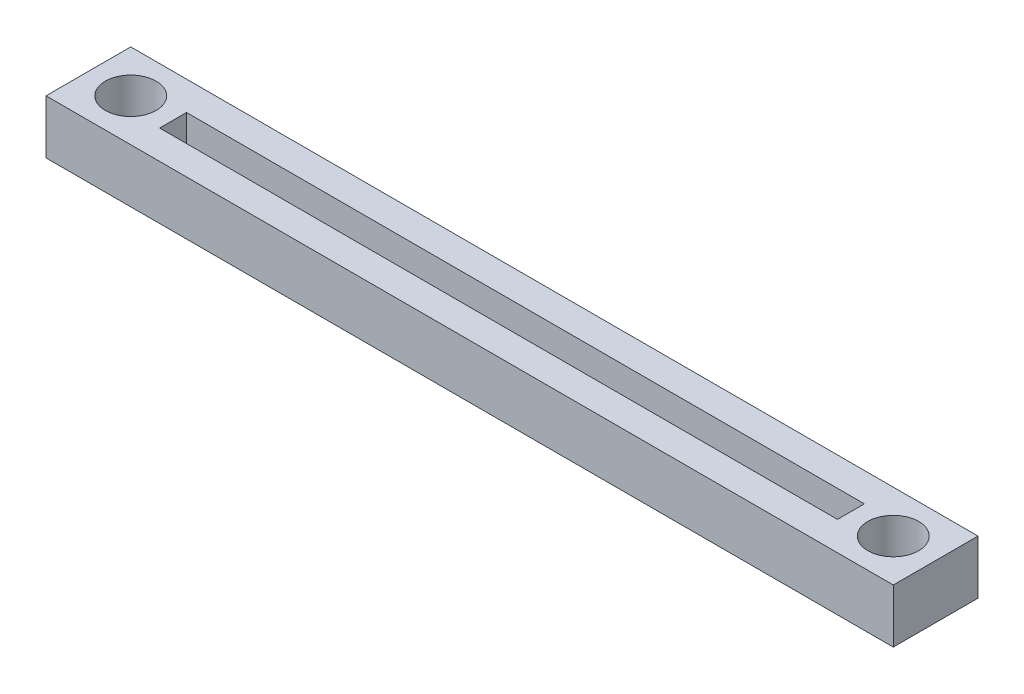
from build123d import *

# Parameters (mm, degrees)
SKETCH1_W                 = 100
SKETCH1_H                 = 10
BOSS_EXTRUDE1_DEPTH       = 6.35
SKETCH2_W                 = 80
SKETCH2_H                 = 3.175
CUT_EXTRUDE1_DEPTH        = 6.35
F_6_0MM_DOWEL_HOLE1_D     = 6
F_6_0MM_DOWEL_HOLE1_DEPTH = 20
F_6_0MM_DOWEL_HOLE1_TIP   = 1.802581857


with BuildPart() as part:
    # Sketch1 → Boss-Extrude1 (new body)
    with BuildSketch(Plane(origin=(0, 0, 0), x_dir=(1, 0, 0), z_dir=(0, 1, 0))):
        Rectangle(SKETCH1_W, SKETCH1_H)
    extrude(amount=BOSS_EXTRUDE1_DEPTH)

    # Sketch2 → Cut-Extrude1 (cut)
    with BuildSketch(Plane(origin=(0, 6.35, 0), x_dir=(1, 0, 0), z_dir=(0, 1, 0))):
        Rectangle(SKETCH2_W, SKETCH2_H)
    extrude(amount=-CUT_EXTRUDE1_DEPTH, mode=Mode.SUBTRACT)

    # Ø6.0mm Dowel Hole1
    with Locations(Plane(origin=(0, 6.35, 0), x_dir=(1, 0, 0), z_dir=(0, 1, 0))):
        with Locations((-45, 0), (45, 0)):
            Hole(F_6_0MM_DOWEL_HOLE1_D / 2, depth=F_6_0MM_DOWEL_HOLE1_DEPTH)
            with Locations((0, 0, -(F_6_0MM_DOWEL_HOLE1_DEPTH + F_6_0MM_DOWEL_HOLE1_TIP / 2))):  # 118° drill point
                Cone(0, F_6_0MM_DOWEL_HOLE1_D / 2, F_6_0MM_DOWEL_HOLE1_TIP, mode=Mode.SUBTRACT)


solid = part.part
